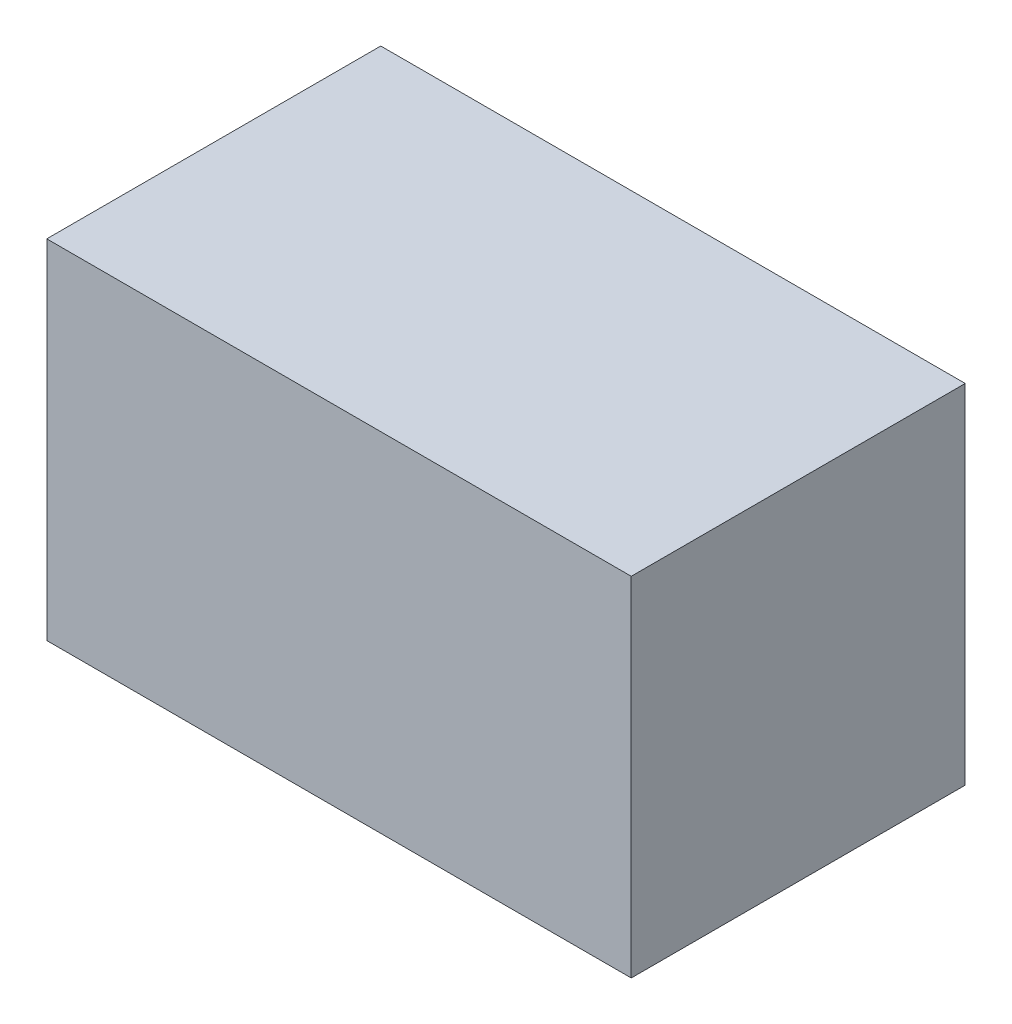
from build123d import *

# Parameters (mm, degrees)
SKETCH1_W           = 84
SKETCH1_H           = 48
BOSS_EXTRUDE1_DEPTH = 50


with BuildPart() as part:
    # Sketch1 → Boss-Extrude1 (new body)
    with BuildSketch(Plane(origin=(0, 0, 0), x_dir=(1, 0, 0), z_dir=(0, 1, 0))):
        with Locations((42, 24)):
            Rectangle(SKETCH1_W, SKETCH1_H)
    extrude(amount=BOSS_EXTRUDE1_DEPTH)


solid = part.part
